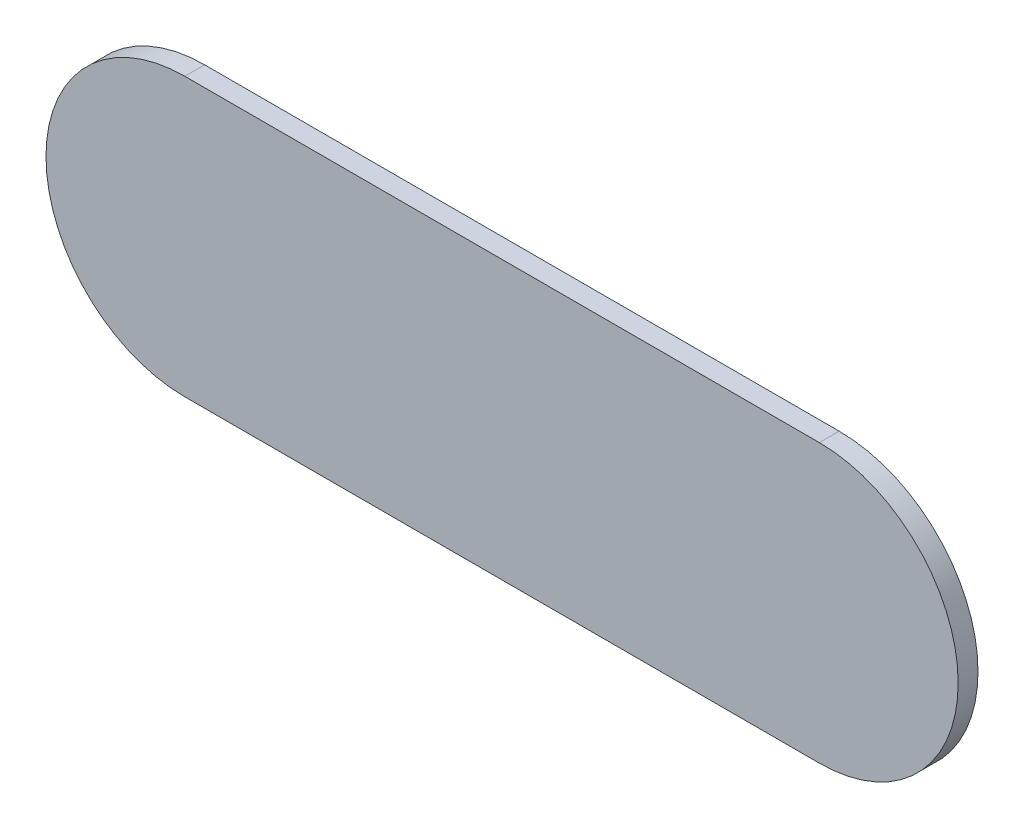
from build123d import *

# Parameters (mm, degrees)
BOSS_EXTRUDE1_DEPTH = 1.5875


with BuildPart() as part:
    # Sketch1 → Boss-Extrude1 (new body)
    with BuildSketch(Plane.XY):
        with BuildLine():
            Line((0, 11.1125), (50.8, 11.1125))
            ThreePointArc((50.8, 11.1125), (61.9125, 0), (50.8, -11.1125))
            Line((50.8, -11.1125), (0, -11.1125))
            ThreePointArc((0, -11.1125), (-11.1125, 0), (0, 11.1125))
        make_face()
    extrude(amount=BOSS_EXTRUDE1_DEPTH)


solid = part.part
